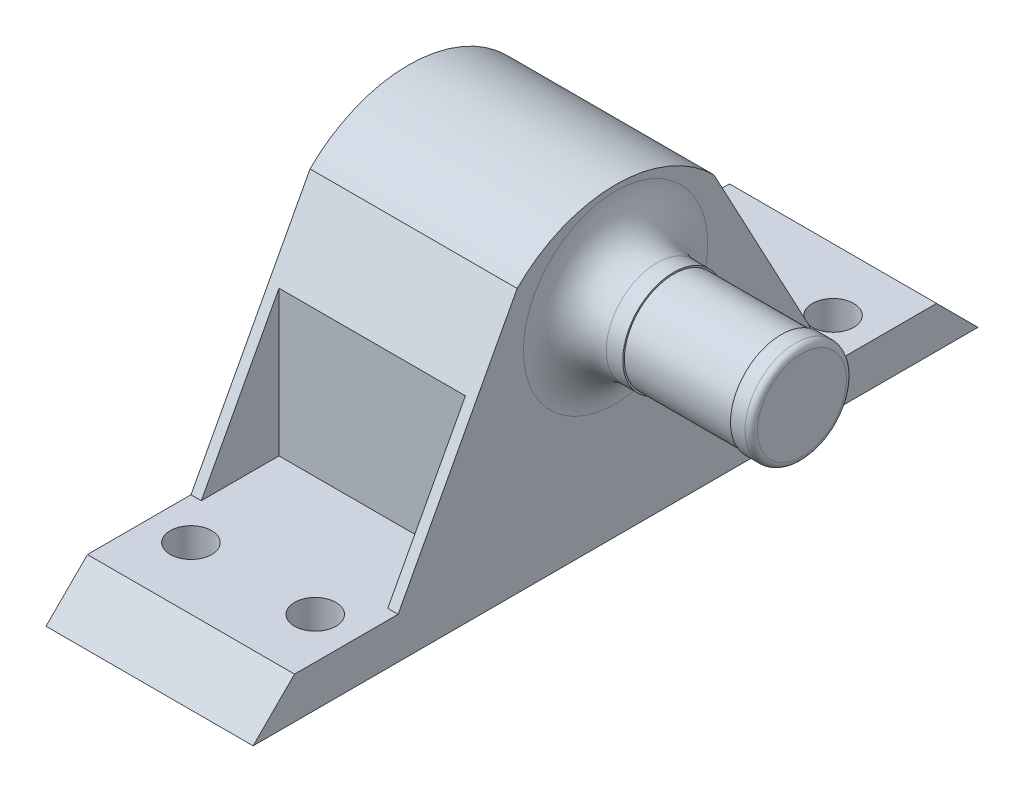
from build123d import *

# Parameters (mm, degrees)
SKETCH2_W                 = 200
SKETCH2_H                 = 200
BOSS_EXTRUDE2_DEPTH       = 60
BOSS_EXTRUDE3_START       = -38
BOSS_EXTRUDE3_DEPTH       = 41
SKETCH5_W                 = 180
SKETCH5_H                 = 180
CUT_EXTRUDE2_DEPTH        = 50
BOSS_EXTRUDE4_START       = -81.2
BOSS_EXTRUDE4_DEPTH       = 30
CUT_EXTRUDE3_DEPTH        = 35
CUT_EXTRUDE4_DEPTH        = 10
CUT_EXTRUDE6_START        = -26
CUT_EXTRUDE6_DEPTH        = 26
SKETCH11_W                = 120
SKETCH11_H                = 10
CUT_EXTRUDE7_DEPTH        = 26
SKETCH12_W                = 180
SKETCH12_H                = 50
CUT_EXTRUDE8_DEPTH        = 200
SKETCH13_W                = 180
SKETCH13_H                = 50
CUT_EXTRUDE9_DEPTH        = 200
SKETCH15_W                = 19.8
SKETCH15_H                = 40.6
CUT_EXTRUDE11_DEPTH       = 10
BOSS_EXTRUDE5_DEPTH       = 26
SKETCH20_W                = 19.8
SKETCH20_H                = 7
CUT_EXTRUDE14_DEPTH       = 8.2
SKETCH22_W                = 22
SKETCH22_H                = 68.38628635
SKETCH22_W_2              = 33
SKETCH22_H_2              = 70.357034464
CUT_EXTRUDE16_DEPTH       = 6
CUT_EXTRUDE17_DEPTH       = 150
SKETCH24_W                = 190
SKETCH24_H                = 55
CUT_EXTRUDE18_DEPTH       = 200
SKETCH41_W                = 200
SKETCH41_H                = 200
SKETCH41_W_2              = 115.381197846
SKETCH41_H_2              = 110.8
CUT_EXTRUDE25_DEPTH       = 100
CUT_EXTRUDE26_DEPTH       = 26
SKETCH43_R                = 85
BOSS_EXTRUDE9_DEPTH       = 5
CUT_EXTRUDE27_DEPTH       = 11
BOSS_EXTRUDE10_DEPTH      = 4
BOSS_EXTRUDE11_DEPTH      = 24
BOSS_EXTRUDE12_DEPTH      = 26
BOSS_EXTRUDE14_DEPTH      = 4
CUT_EXTRUDE29_DEPTH       = 18
CUT_EXTRUDE30_DEPTH       = 2
CUT_EXTRUDE31_DEPTH       = 2
SKETCH55_W                = 19.8
SKETCH55_H                = 2.410200662
BOSS_EXTRUDE16_DEPTH      = 4
SKETCH56_W                = 22
SKETCH56_H                = 70.356823689
CUT_EXTRUDE32_DEPTH       = 4
BOSS_EXTRUDE17_DEPTH      = 26
BOSS_EXTRUDE18_DEPTH      = 26
BOSS_EXTRUDE19_START      = 170
BOSS_EXTRUDE19_DEPTH      = 10
SKETCH60_R                = 2.45
BOSS_EXTRUDE20_DEPTH      = 9
FILLET1_R                 = 0.3
CUT_EXTRUDE33_START       = -1
SKETCH61_R                = 2.45
SKETCH61_R_2              = 2.375
CUT_EXTRUDE33_DEPTH       = 5.2
FILLET2_R                 = 2
BOSS_EXTRUDE21_START      = 140
BOSS_EXTRUDE21_DEPTH      = 10
SKETCH63_R                = 2.45
BOSS_EXTRUDE22_DEPTH      = 9
FILLET3_R                 = 0.3
FILLET4_R                 = 2
CUT_EXTRUDE34_START       = -1
SKETCH64_R                = 2.45
SKETCH64_R_2              = 2.375
CUT_EXTRUDE34_DEPTH       = 5.2
SKETCH67_R                = 95.168377016
SKETCH67_R_2              = 84.75
CUT_EXTRUDE36_DEPTH       = 5
CUT_EXTRUDE37_DEPTH       = 300
CUT_EXTRUDE37_DEPTH_BACK  = 300
F_2_0MM_DOWEL_HOLE1_D     = 2
F_2_0MM_DOWEL_HOLE1_DEPTH = 10
F_2_0MM_DOWEL_HOLE1_TIP   = 0.600860619
CUT_EXTRUDE39_START       = -2
SKETCH74_W                = 9
SKETCH74_H                = 11.89890002
SKETCH74_H_2              = 12.887833041
CUT_EXTRUDE39_DEPTH       = 300
SKETCH75_W                = 5
SKETCH75_H                = 5
CUT_EXTRUDE40_DEPTH       = 300
CUT_EXTRUDE41_DEPTH       = 300


with BuildPart() as part:
    # Sketch2 → Boss-Extrude2 (new body)
    with BuildSketch(Plane(origin=(0, 0, 0), x_dir=(1, 0, 0), z_dir=(0, 1, 0))):
        with Locations((100, 100)):
            Rectangle(SKETCH2_W, SKETCH2_H)
    extrude(amount=BOSS_EXTRUDE2_DEPTH)

    # Sketch3 → Boss-Extrude3 (add)
    with BuildSketch(Plane.XY.offset(BOSS_EXTRUDE3_START)):
        with BuildLine():
            Line((40, 60), (80.980762114, 130.980762114))
            ThreePointArc((80.980762114, 130.980762114), (100, 141.961524227), (119.019237886, 130.980762114))
            Line((119.019237886, 130.980762114), (160, 60))
            Line((160, 60), (40, 60))
        make_face()
    extrude(amount=-BOSS_EXTRUDE3_DEPTH)

    # Sketch5 → Cut-Extrude2 (cut)
    with BuildSketch(Plane.XZ):
        with Locations((100, -100)):
            Rectangle(SKETCH5_W, SKETCH5_H)
    extrude(amount=-CUT_EXTRUDE2_DEPTH, mode=Mode.SUBTRACT)

    # Sketch7 → Boss-Extrude4 (add)
    with BuildSketch(Plane(origin=(0, 0, -200), x_dir=(-1, 0, 0), z_dir=(0, 0, -1)).offset(BOSS_EXTRUDE4_START)):
        with BuildLine():
            Line((-160, 60), (-40, 60))
            Line((-40, 60), (-80.980762114, 130.980762114))
            ThreePointArc((-80.980762114, 130.980762114), (-100, 141.961524227), (-119.019237886, 130.980762114))
            Line((-119.019237886, 130.980762114), (-160, 60))
        make_face()
    extrude(amount=BOSS_EXTRUDE4_DEPTH)

    # Sketch8 → Cut-Extrude3 (cut)
    with BuildSketch(Plane.XY.offset(-38)):
        with BuildLine():
            Line((48.660254038, 65), (151.339745962, 65))
            Line((151.339745962, 65), (114.689110868, 128.480762114))
            ThreePointArc((114.689110868, 128.480762114), (100, 136.961524227), (85.310889132, 128.480762114))
            Line((85.310889132, 128.480762114), (48.660254038, 65))
        make_face()
    extrude(amount=-CUT_EXTRUDE3_DEPTH, mode=Mode.SUBTRACT)

    # Sketch9 → Cut-Extrude4 (cut)
    with BuildSketch(Plane.XY.offset(-118.8)):
        with BuildLine():
            Line((95, 141.384773704), (95, 105))
            ThreePointArc((95, 105), (100, 100), (105, 105))
            Line((105, 105), (105, 141.384773704))
            ThreePointArc((105, 141.384773704), (100, 141.961524227), (95, 141.384773704))
        make_face()
    extrude(amount=-CUT_EXTRUDE4_DEPTH, mode=Mode.SUBTRACT)

    # Sketch10 → Cut-Extrude6 (cut)
    with BuildSketch(Plane(origin=(0, 0, -148.8), x_dir=(-1, 0, 0), z_dir=(0, 0, -1)).offset(CUT_EXTRUDE6_START)):
        with BuildLine():
            Line((-114.689110868, 128.480762114), (-151.339745962, 65))
            Line((-151.339745962, 65), (-48.660254038, 65))
            Line((-48.660254038, 65), (-85.310889132, 128.480762114))
            ThreePointArc((-85.310889132, 128.480762114), (-87.382612213, 131.335555987), (-90, 133.700120587))
            Line((-90, 133.700120587), (-90, 105))
            ThreePointArc((-90, 105), (-100, 95), (-110, 105))
            Line((-110, 105), (-110, 133.700120587))
            ThreePointArc((-110, 133.700120587), (-112.617387787, 131.335555987), (-114.689110868, 128.480762114))
        make_face()
    extrude(amount=CUT_EXTRUDE6_DEPTH, mode=Mode.SUBTRACT)

    # Sketch11 → Cut-Extrude7 (cut)
    with BuildSketch(Plane(origin=(0, 60, 0), x_dir=(1, 0, 0), z_dir=(0, 1, 0))):
        with Locations((100, 113.8)):
            Rectangle(SKETCH11_W, SKETCH11_H)
    extrude(amount=-CUT_EXTRUDE7_DEPTH, mode=Mode.SUBTRACT)

    # Sketch12 → Cut-Extrude8 (cut)
    with BuildSketch(Plane(origin=(200, 0, 0), x_dir=(0, 0, -1), z_dir=(1, 0, 0))):
        with Locations((100, 25)):
            Rectangle(SKETCH12_W, SKETCH12_H)
    extrude(amount=-CUT_EXTRUDE8_DEPTH, mode=Mode.SUBTRACT)

    # Sketch13 → Cut-Extrude9 (cut)
    with BuildSketch(Plane.XY):
        with Locations((100, 25)):
            Rectangle(SKETCH13_W, SKETCH13_H)
    extrude(amount=-CUT_EXTRUDE9_DEPTH, mode=Mode.SUBTRACT)

    # Sketch15 → Cut-Extrude11 (cut)
    with BuildSketch(Plane.XY.offset(-73)):
        with Locations((100, 94.7)):
            Rectangle(SKETCH15_W, SKETCH15_H)
    extrude(amount=-CUT_EXTRUDE11_DEPTH, mode=Mode.SUBTRACT)

    # Sketch16 → Boss-Extrude5 (add)
    with BuildSketch(Plane.XY.offset(-73)):
        Polygon((88.1, 115), (88.1, 72.4), (111.9, 72.4), (111.9, 115), (109.9, 115), (109.9, 74.4), (90.1, 74.4), (90.1, 115), align=None)
    extrude(amount=BOSS_EXTRUDE5_DEPTH)

    # Sketch20 → Cut-Extrude14 (cut)
    with BuildSketch(Plane(origin=(0, 0, -79), x_dir=(-1, 0, 0), z_dir=(0, 0, -1))):
        with Locations((-100, 118.5)):
            Rectangle(SKETCH20_W, SKETCH20_H)
        with Locations((-100, 70.9)):
            Rectangle(SKETCH20_W, SKETCH20_H)
    extrude(amount=-CUT_EXTRUDE14_DEPTH, mode=Mode.SUBTRACT)

    # Sketch22 → Cut-Extrude16 (cut)
    with BuildSketch(Plane(origin=(4.019237886, -2.320508076, 0), x_dir=(0, 0, 1), z_dir=(-0.8660254037844397, 0.49999999999999806, 0))):
        with Locations((-133.8, 115.729905279)):
            Rectangle(SKETCH22_W, SKETCH22_H)
        with Locations((-58.5, 116.744531222)):
            Rectangle(SKETCH22_W_2, SKETCH22_H_2)
    extrude(amount=-CUT_EXTRUDE16_DEPTH, mode=Mode.SUBTRACT)

    # Sketch23 → Cut-Extrude17 (cut)
    with BuildSketch(Plane.XY.offset(-38)):
        with BuildLine():
            Line((43.464101615, 62), (42.309401077, 60))
            Line((42.309401077, 60), (36.951802896, 60))
            Line((36.951802896, 60), (100, 183.688158135))
            Line((100, 183.688158135), (162.604774917, 60))
            Line((162.604774917, 60), (157.690598923, 60))
            Line((157.690598923, 60), (156.535898385, 62))
            Line((156.535898385, 62), (117.287187079, 129.980762114))
            ThreePointArc((117.287187079, 129.980762114), (100, 139.961524227), (82.712812921, 129.980762114))
            Line((82.712812921, 129.980762114), (43.464101615, 62))
        make_face()
    extrude(amount=-CUT_EXTRUDE17_DEPTH, mode=Mode.SUBTRACT)

    # Sketch24 → Cut-Extrude18 (cut)
    with BuildSketch(Plane(origin=(0, 0, -200), x_dir=(-1, 0, 0), z_dir=(0, 0, -1))):
        with Locations((-100, 27.5)):
            Rectangle(SKETCH24_W, SKETCH24_H)
    extrude(amount=-CUT_EXTRUDE18_DEPTH, mode=Mode.SUBTRACT)

    # Sketch41 → Cut-Extrude25 (cut)
    with BuildSketch(Plane(origin=(0, 60, 0), x_dir=(1, 0, 0), z_dir=(0, 1, 0))):
        with Locations((100, 100)):
            Rectangle(SKETCH41_W, SKETCH41_H)
        with Locations((100, 93.4)):
            Rectangle(SKETCH41_W_2, SKETCH41_H_2, mode=Mode.SUBTRACT)
    extrude(amount=-CUT_EXTRUDE25_DEPTH, mode=Mode.SUBTRACT)


with BuildPart() as cut_extrude25_piece_1:
    # of the separate pieces the step leaves, piece 1, a body of its own (cut_extrude25_pieces)
    add(part.part.solids().sort_by_distance((42.309401077, 55, -108.8))[0])



with BuildPart() as cut_extrude25_piece_2:
    # of the separate pieces the step leaves, piece 2, a body of its own (cut_extrude25_pieces)
    add(part.part.solids().sort_by_distance((42.309401077, 55, -118.8))[0])

    # Sketch38 → Cut-Extrude26 (cut)
    with BuildSketch(Plane(origin=(0, 0, -148.8), x_dir=(-1, 0, 0), z_dir=(0, 0, -1))):
        with BuildLine():
            Line((-110, 133.700120587), (-107, 135.763853262))
            Line((-107, 135.763853262), (-107, 105))
            ThreePointArc((-107, 105), (-100, 98), (-93, 105))
            Line((-93, 105), (-93, 135.763853262))
            Line((-93, 135.763853262), (-90, 133.700120587))
            Line((-90, 133.700120587), (-90, 105))
            ThreePointArc((-90, 105), (-100, 95), (-110, 105))
            Line((-110, 105), (-110, 133.700120587))
        make_face()
    extrude(amount=-CUT_EXTRUDE26_DEPTH, mode=Mode.SUBTRACT)


with BuildPart() as cut_extrude25_piece_1_1:
    add(cut_extrude25_piece_1.part)

    add(cut_extrude25_piece_2.part)  # Boss-Extrude9 merges Cut-Extrude25 piece 2
    # Sketch43 → Boss-Extrude9 (add)
    with BuildSketch(Plane.XZ.offset(-55)):
        with Locations((100, -98.8)):
            Circle(SKETCH43_R)
    extrude(amount=-BOSS_EXTRUDE9_DEPTH)

    # Sketch45 → Cut-Extrude27 (cut)
    with BuildSketch(Plane.XY.offset(-38)):
        with BuildLine():
            Line((42.309401077, 60), (82.712812921, 129.980762114))
            ThreePointArc((82.712812921, 129.980762114), (100, 139.961524227), (117.287187079, 129.980762114))
            Line((117.287187079, 129.980762114), (157.690598923, 60))
            Line((157.690598923, 60), (42.309401077, 60))
        make_face()
        with BuildLine():
            Line((151.339745962, 65), (114.689110868, 128.480762114))
            ThreePointArc((114.689110868, 128.480762114), (100, 136.961524227), (85.310889132, 128.480762114))
            Line((85.310889132, 128.480762114), (48.660254038, 65))
            Line((48.660254038, 65), (151.339745962, 65))
        make_face(mode=Mode.SUBTRACT)
    extrude(amount=-CUT_EXTRUDE27_DEPTH, mode=Mode.SUBTRACT)

    # Sketch46 → Boss-Extrude10 (add)
    with BuildSketch(Plane.XY.offset(-49)):
        Polygon((81.712812921, 128.248711306), (46.534295689, 67.317732125), (49.094273419, 65.839728294), (84.272790651, 126.770707475), align=None)
    extrude(amount=-BOSS_EXTRUDE10_DEPTH)

    # Sketch47 → Boss-Extrude11 (add)
    with BuildSketch(Plane.XY.offset(-73)):
        Polygon((49.1323719, 65.817732125), (50.548725488, 65), (48.660254038, 65), align=None)
    extrude(amount=BOSS_EXTRUDE11_DEPTH)

    # Sketch48 → Boss-Extrude12 (add)
    with BuildSketch(Plane(origin=(0, 0, -122.8), x_dir=(-1, 0, 0), z_dir=(0, 0, -1))):
        Polygon((-49.117745958, 65.792399249), (-50.490221717, 65), (-48.660254038, 65), align=None)
    extrude(amount=BOSS_EXTRUDE12_DEPTH)

    # Sketch49 → Boss-Extrude14 (add)
    with BuildSketch(Plane.XY.offset(-75)):
        Polygon((49.998397304, 65.317732125), (49.094273419, 65.839728294), (84.272790651, 126.770707475), (85.176914536, 126.248711306), align=None)
    extrude(amount=BOSS_EXTRUDE14_DEPTH)

    # Sketch52 → Cut-Extrude29 (cut)
    with BuildSketch(Plane(origin=(0, 0, -148.8), x_dir=(-1, 0, 0), z_dir=(0, 0, -1))):
        with BuildLine():
            Line((-93, 135.763853262), (-93, 105))
            ThreePointArc((-93, 105), (-100, 98), (-107, 105))
            Line((-107, 105), (-107, 135.763853262))
            ThreePointArc((-107, 135.763853262), (-100, 137.248161341), (-93, 135.763853262))
        make_face()
    extrude(amount=-CUT_EXTRUDE29_DEPTH, mode=Mode.SUBTRACT)

    # Sketch53 → Cut-Extrude30 (cut)
    with BuildSketch(Plane.XY.offset(-71)):
        Polygon((85.176914536, 126.248711306), (84.272790651, 126.770707475), (49.090707581, 65.833552081), (49.994831466, 65.311555913), align=None)
    extrude(amount=-CUT_EXTRUDE30_DEPTH, mode=Mode.SUBTRACT)

    # Sketch54 → Cut-Extrude31 (cut)
    with BuildSketch(Plane.XY.offset(-73)):
        with BuildLine():
            Line((50.548725488, 65), (151.339745962, 65))
            Line((151.339745962, 65), (114.689110868, 128.480762114))
            ThreePointArc((114.689110868, 128.480762114), (100, 136.961524227), (85.310889132, 128.480762114))
            Line((85.310889132, 128.480762114), (84.310889132, 126.748711306))
            Line((84.310889132, 126.748711306), (84.272790651, 126.770707475))
            Line((84.272790651, 126.770707475), (49.094273419, 65.839728294))
            Line((49.094273419, 65.839728294), (49.090707581, 65.833552081))
            Line((49.090707581, 65.833552081), (49.994831466, 65.311555913))
            Line((49.994831466, 65.311555913), (49.998397304, 65.317732125))
            Line((49.998397304, 65.317732125), (50.548725488, 65))
        make_face()
        Polygon((109.9, 67.4), (90.1, 67.4), (90.1, 72.4), (88.1, 72.4), (88.1, 115), (90.1, 115), (90.1, 122), (109.9, 122), (109.9, 115), (111.9, 115), (111.9, 72.4), (109.9, 72.4), align=None, mode=Mode.SUBTRACT)
    extrude(amount=-CUT_EXTRUDE31_DEPTH, mode=Mode.SUBTRACT)

    # Sketch55 → Boss-Extrude16 (add)
    with BuildSketch(Plane.XY.offset(-75)):
        with Locations((100, 66.194899669)):
            Rectangle(SKETCH55_W, SKETCH55_H)
    extrude(amount=BOSS_EXTRUDE16_DEPTH)

    # Sketch56 → Cut-Extrude32 (cut)
    with BuildSketch(Plane(origin=(144.248711306, 83.282032303, 0), x_dir=(0, 0, -1), z_dir=(0.8660254037844362, 0.5000000000000044, 0))):
        with Locations((64, 16.744636609)):
            Rectangle(SKETCH56_W, SKETCH56_H)
        with Locations((133.8, 16.744636609)):
            Rectangle(SKETCH56_W, SKETCH56_H)
    extrude(amount=-CUT_EXTRUDE32_DEPTH, mode=Mode.SUBTRACT)

    # Sketch57 → Boss-Extrude17 (add)
    with BuildSketch(Plane.XY.offset(-75)):
        Polygon((150.867522712, 65.817914662), (149.450852961, 65), (151.339745962, 65), align=None)
    extrude(amount=BOSS_EXTRUDE17_DEPTH)

    # Sketch58 → Boss-Extrude18 (add)
    with BuildSketch(Plane(origin=(0, 0, -122.8), x_dir=(-1, 0, 0), z_dir=(0, 0, -1))):
        Polygon((-150.867522712, 65.817914662), (-151.339745962, 65), (-149.450852961, 65), align=None)
    extrude(amount=BOSS_EXTRUDE18_DEPTH)

    # Sketch59 → Boss-Extrude19 (add)
    with BuildSketch(Plane(origin=(0, 0, 0), x_dir=(0, 0, -1), z_dir=(1, 0, 0)).offset(BOSS_EXTRUDE19_START)):
        with BuildLine():
            Line((81.4, 60), (94.15, 72.75))
            ThreePointArc((94.15, 72.75), (98.9, 74.717514421), (103.65, 72.75))
            Line((103.65, 72.75), (116.4, 60))
            Line((116.4, 60), (81.4, 60))
        make_face()
        with BuildLine():
            Line((81.4, 55), (116.4, 55))
            Line((116.4, 55), (103.65, 42.25))
            ThreePointArc((103.65, 42.25), (98.9, 40.282485579), (94.15, 42.25))
            Line((94.15, 42.25), (81.4, 55))
        make_face()
    extrude(amount=BOSS_EXTRUDE19_DEPTH)

    # Sketch60 → Boss-Extrude20 (add)
    with BuildSketch(Plane(origin=(180, 0, 0), x_dir=(0, 0, -1), z_dir=(1, 0, 0))):
        with Locations((98.9, 70)):
            Circle(SKETCH60_R)
        with Locations((98.9, 45)):
            Circle(SKETCH60_R)
    extrude(amount=BOSS_EXTRUDE20_DEPTH)

    # Fillet1
    fillet1_edges = [cut_extrude25_piece_1_1.edges().sort_by_distance(p)[0] for p in [
        (189, 70, -96.45),
        (189, 45, -96.45),
    ]]
    fillet(fillet1_edges, radius=FILLET1_R)

    # Sketch61 → Cut-Extrude33 (cut)
    # profile 1 of 2: a face of its own
    with BuildSketch(Plane(origin=(189, 0, 0), x_dir=(0, 0, -1), z_dir=(1, 0, 0)).offset(CUT_EXTRUDE33_START)):
        with Locations((98.9, 70)):
            Circle(SKETCH61_R)
        with Locations((98.9, 70)):
            Circle(SKETCH61_R_2, mode=Mode.SUBTRACT)
    # profile 2 of 2: a face of its own
    with BuildSketch(Plane(origin=(189, 0, 0), x_dir=(0, 0, -1), z_dir=(1, 0, 0)).offset(CUT_EXTRUDE33_START)):
        with Locations((98.9, 45)):
            Circle(SKETCH61_R)
        with Locations((98.9, 45)):
            Circle(SKETCH61_R_2, mode=Mode.SUBTRACT)
    extrude(amount=-CUT_EXTRUDE33_DEPTH, mode=Mode.SUBTRACT)

    # Fillet2
    fillet2_edges = [cut_extrude25_piece_1_1.edges().sort_by_distance(p)[0] for p in [
        (180, 70, -96.45),
        (180, 45, -96.45),
    ]]
    fillet(fillet2_edges, radius=FILLET2_R)

    # Sketch62 → Boss-Extrude21 (add)
    with BuildSketch(Plane.ZY.offset(-170).offset(BOSS_EXTRUDE21_START)):
        with BuildLine():
            Line((-81.4, 55), (-94.15, 42.25))
            ThreePointArc((-94.15, 42.25), (-98.9, 40.282485579), (-103.65, 42.25))
            Line((-103.65, 42.25), (-116.4, 55))
            Line((-116.4, 55), (-81.4, 55))
        make_face()
    extrude(amount=BOSS_EXTRUDE21_DEPTH)

    # Sketch63 → Boss-Extrude22 (add)
    with BuildSketch(Plane.ZY.offset(-20)):
        with Locations((-98.9, 45)):
            Circle(SKETCH63_R)
    extrude(amount=BOSS_EXTRUDE22_DEPTH)

    # Fillet3
    fillet3_edges = [cut_extrude25_piece_1_1.edges().sort_by_distance(p)[0] for p in [
        (11, 45, -101.35),
    ]]
    fillet(fillet3_edges, radius=FILLET3_R)

    # Fillet4
    fillet4_edges = [cut_extrude25_piece_1_1.edges().sort_by_distance(p)[0] for p in [
        (20, 45, -101.35),
    ]]
    fillet(fillet4_edges, radius=FILLET4_R)

    # Sketch64 → Cut-Extrude34 (cut)
    with BuildSketch(Plane.ZY.offset(-11).offset(CUT_EXTRUDE34_START)):
        with Locations((-98.9, 45)):
            Circle(SKETCH64_R)
        with Locations((-98.9, 45)):
            Circle(SKETCH64_R_2, mode=Mode.SUBTRACT)
    extrude(amount=-CUT_EXTRUDE34_DEPTH, mode=Mode.SUBTRACT)

    # Sketch67 → Cut-Extrude36 (cut)
    with BuildSketch(Plane(origin=(0, 60, 0), x_dir=(1, 0, 0), z_dir=(0, 1, 0))):
        with Locations((100, 98.8)):
            Circle(SKETCH67_R)
        with Locations((100, 98.8)):
            Circle(SKETCH67_R_2, mode=Mode.SUBTRACT)
    extrude(amount=-CUT_EXTRUDE36_DEPTH, mode=Mode.SUBTRACT)

    # Sketch69 → Cut-Extrude37 (cut, two sides: drawn at the far end of the back side and taken through both)
    with BuildSketch(Plane.XY.offset(-49).offset(-CUT_EXTRUDE37_DEPTH_BACK)):
        Polygon((170, 23.542190337), (-15.62420472, 23.542190337), (-15.62420472, 153.961909404), (170, 153.961909404), (170, 60), (192.608960178, 60), (192.608960178, 23.542190337), align=None)
    extrude(amount=CUT_EXTRUDE37_DEPTH + CUT_EXTRUDE37_DEPTH_BACK, mode=Mode.SUBTRACT)

    # Ø2.0mm Dowel Hole1
    with Locations(Plane(origin=(172, 60, -86.4), x_dir=(0, 0, -1), z_dir=(0, -1, 0))):
        with Locations((0, 0), (0, 6), (25, 0), (25, 6)):
            Hole(F_2_0MM_DOWEL_HOLE1_D / 2, depth=F_2_0MM_DOWEL_HOLE1_DEPTH)
            with Locations((0, 0, -(F_2_0MM_DOWEL_HOLE1_DEPTH + F_2_0MM_DOWEL_HOLE1_TIP / 2))):  # 118° drill point
                Cone(0, F_2_0MM_DOWEL_HOLE1_D / 2, F_2_0MM_DOWEL_HOLE1_TIP, mode=Mode.SUBTRACT)

    # Sketch74 → Cut-Extrude39 (cut)
    with BuildSketch(Plane.XZ.offset(-60).offset(CUT_EXTRUDE39_START)):
        with Locations((175, -111.59945001)):
            Rectangle(SKETCH74_W, SKETCH74_H)
        with Locations((175, -85.706083479)):
            Rectangle(SKETCH74_W, SKETCH74_H_2)
    extrude(amount=-CUT_EXTRUDE39_DEPTH, mode=Mode.SUBTRACT)

    # Sketch75 → Cut-Extrude40 (cut)
    with BuildSketch(Plane.ZY.offset(-170)):
        with Locations((-111.9, 64.5)):
            Rectangle(SKETCH75_W, SKETCH75_H)
        with Locations((-85.9, 64.5)):
            Rectangle(SKETCH75_W, SKETCH75_H)
    extrude(amount=-CUT_EXTRUDE40_DEPTH, mode=Mode.SUBTRACT)

    # Sketch76 → Cut-Extrude41 (cut)
    with BuildSketch(Plane.ZY.offset(-170)):
        Polygon((-103.65, 72.75), (-109.4, 62), (-109.4, 67), align=None)
        Polygon((-88.4, 62), (-94.15, 72.75), (-88.4, 67), align=None)
    extrude(amount=-CUT_EXTRUDE41_DEPTH, mode=Mode.SUBTRACT)


solid = cut_extrude25_piece_1_1.part
